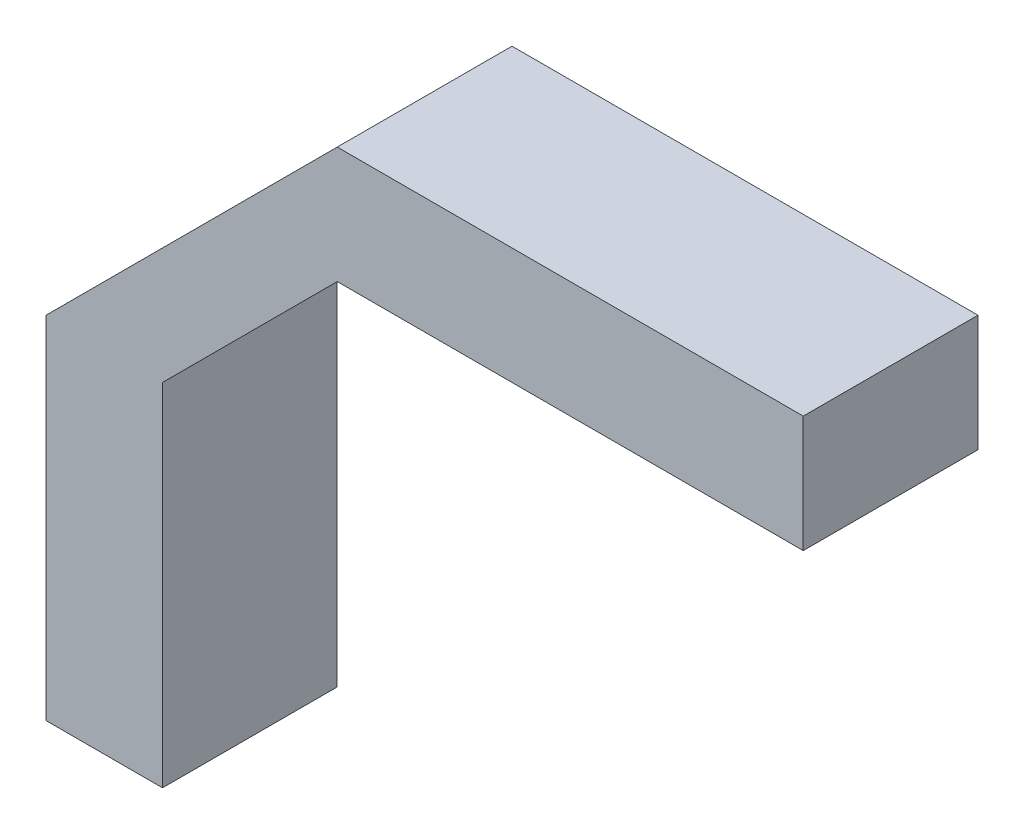
from build123d import *

# Parameters (mm, degrees)
BOSS_EXTRUDE1_DEPTH = 7.5


with BuildPart() as part:
    # Sketch1 → Boss-Extrude1 (new body, symmetric)
    with BuildSketch(Plane.XY):
        Polygon((0, 0), (10, 0), (10, 30.133465151), (25, 45.133465151), (65, 45.133465151), (65, 55.133465151), (25, 55.133465151), (0, 30.133465151), align=None)
    extrude(amount=BOSS_EXTRUDE1_DEPTH, both=True)


solid = part.part
